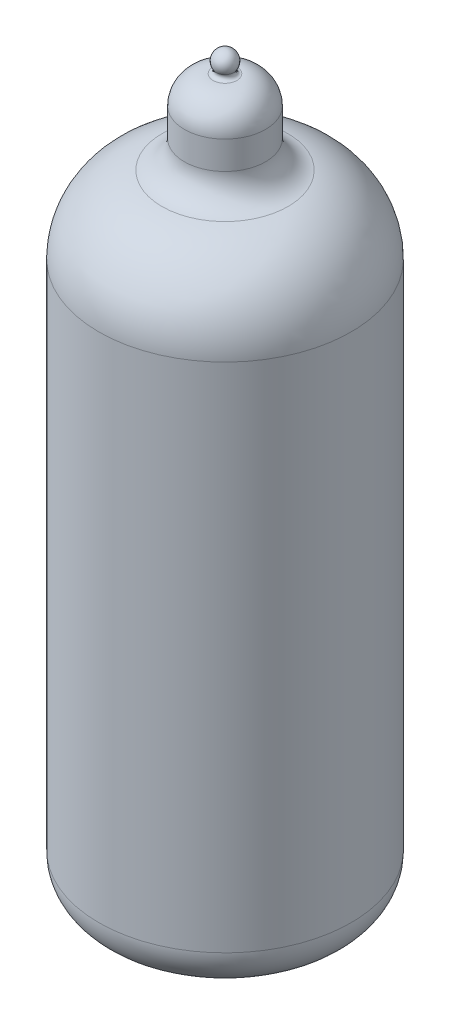
from build123d import *

# Parameters (mm, degrees)
CUT_EXTRUDE1_REACH = 54.5
SKETCH2_R          = 0.25
SKETCH3_R          = 3
CUT_EXTRUDE2_DEPTH = 0.5
CUT_EXTRUDE2_TAPER = 15


with BuildPart() as part:
    # Sketch1 → Revolve1 (revolve)
    with BuildSketch(Plane.XY):
        with BuildLine():
            Line((0, -26.25), (-6, -26.25))
            ThreePointArc((-6, -26.25), (-8.121320344, -25.371320344), (-9, -23.25))
            Line((-9, -23.25), (-9, 13.25))
            ThreePointArc((-9, 13.25), (-7.73164929, 16.803167601), (-4.5, 18.75))
            ThreePointArc((-4.5, 18.75), (-3.348125006, 19.443920459), (-2.896039604, 20.71039604))
            Line((-2.896039604, 20.71039604), (-2.896039604, 22.71039604))
            ThreePointArc((-2.896039604, 22.71039604), (-2.293006224, 24.141648729), (-0.847555343, 24.709808272))
            ThreePointArc((-0.847555343, 24.709808272), (-0.623570884, 24.837222914), (-0.631121107, 25.094801101))
            ThreePointArc((-0.631121107, 25.094801101), (-0.658178993, 25.859583666), (0, 26.25))
            Line((0, 26.25), (0, 24.21039604))
            Line((0, 24.21039604), (-0.896039604, 24.21039604))
            ThreePointArc((-0.896039604, 24.21039604), (-1.956699776, 23.771056211), (-2.396039604, 22.71039604))
            Line((-2.396039604, 22.71039604), (-2.396039604, 20.71039604))
            ThreePointArc((-2.396039604, 20.71039604), (-2.961146356, 19.127301564), (-4.400990099, 18.25990099))
            ThreePointArc((-4.400990099, 18.25990099), (-7.34467064, 16.486548706), (-8.5, 13.25))
            Line((-8.5, 13.25), (-8.5, -21.25))
            ThreePointArc((-8.5, -21.25), (-8.207106781, -21.957106781), (-7.5, -22.25))
            Line((-7.5, -22.25), (0, -22.25))
            Line((0, -22.25), (0, -26.25))
        make_face()
    revolve(axis=Axis((0, 26.25, 0), (0, -1, 0)))

    # Sketch2 → Cut-Extrude1 (cut, up to next)
    with BuildSketch(Plane.XZ.offset(26.25), mode=Mode.PRIVATE) as cut_extrude1_sk1:
        with Locations((0, -5.75)):
            Circle(SKETCH2_R)
    cut_extrude1_tool1 = extrude(cut_extrude1_sk1.sketch, amount=-CUT_EXTRUDE1_REACH, mode=Mode.PRIVATE) & part.part
    add(cut_extrude1_tool1.solids().sort_by_distance((0, -26.25, -5.75))[0], mode=Mode.SUBTRACT)
    # Sketch2 → Cut-Extrude1 (cut, up to next)
    with BuildSketch(Plane.XZ.offset(26.25), mode=Mode.PRIVATE) as cut_extrude1_sk2:
        with Locations((-2.672158239, -5.091372148)):
            Circle(SKETCH2_R)
    cut_extrude1_tool2 = extrude(cut_extrude1_sk2.sketch, amount=-CUT_EXTRUDE1_REACH, mode=Mode.PRIVATE) & part.part
    add(cut_extrude1_tool2.solids().sort_by_distance((-2.672158, -26.25, -5.091372))[0], mode=Mode.SUBTRACT)
    # Sketch2 → Cut-Extrude1 (cut, up to next)
    with BuildSketch(Plane.XZ.offset(26.25), mode=Mode.PRIVATE) as cut_extrude1_sk3:
        with Locations((-4.732157229, -3.266372294)):
            Circle(SKETCH2_R)
    cut_extrude1_tool3 = extrude(cut_extrude1_sk3.sketch, amount=-CUT_EXTRUDE1_REACH, mode=Mode.PRIVATE) & part.part
    add(cut_extrude1_tool3.solids().sort_by_distance((-4.732157, -26.25, -3.266372))[0], mode=Mode.SUBTRACT)
    # Sketch2 → Cut-Extrude1 (cut, up to next)
    with BuildSketch(Plane.XZ.offset(26.25), mode=Mode.PRIVATE) as cut_extrude1_sk4:
        with Locations((-5.708076026, -0.693085911)):
            Circle(SKETCH2_R)
    cut_extrude1_tool4 = extrude(cut_extrude1_sk4.sketch, amount=-CUT_EXTRUDE1_REACH, mode=Mode.PRIVATE) & part.part
    add(cut_extrude1_tool4.solids().sort_by_distance((-5.708076, -26.25, -0.693086))[0], mode=Mode.SUBTRACT)
    # Sketch2 → Cut-Extrude1 (cut, up to next)
    with BuildSketch(Plane.XZ.offset(26.25), mode=Mode.PRIVATE) as cut_extrude1_sk5:
        with Locations((-5.376343395, 2.0389781)):
            Circle(SKETCH2_R)
    cut_extrude1_tool5 = extrude(cut_extrude1_sk5.sketch, amount=-CUT_EXTRUDE1_REACH, mode=Mode.PRIVATE) & part.part
    add(cut_extrude1_tool5.solids().sort_by_distance((-5.376343, -26.25, 2.038978))[0], mode=Mode.SUBTRACT)
    # Sketch2 → Cut-Extrude1 (cut, up to next)
    with BuildSketch(Plane.XZ.offset(26.25), mode=Mode.PRIVATE) as cut_extrude1_sk6:
        with Locations((-3.812955285, 4.303936802)):
            Circle(SKETCH2_R)
    cut_extrude1_tool6 = extrude(cut_extrude1_sk6.sketch, amount=-CUT_EXTRUDE1_REACH, mode=Mode.PRIVATE) & part.part
    add(cut_extrude1_tool6.solids().sort_by_distance((-3.812955, -26.25, 4.303937))[0], mode=Mode.SUBTRACT)
    # Sketch2 → Cut-Extrude1 (cut, up to next)
    with BuildSketch(Plane.XZ.offset(26.25), mode=Mode.PRIVATE) as cut_extrude1_sk7:
        with Locations((-1.37606507, 5.58291545)):
            Circle(SKETCH2_R)
    cut_extrude1_tool7 = extrude(cut_extrude1_sk7.sketch, amount=-CUT_EXTRUDE1_REACH, mode=Mode.PRIVATE) & part.part
    add(cut_extrude1_tool7.solids().sort_by_distance((-1.376065, -26.25, 5.582915))[0], mode=Mode.SUBTRACT)
    # Sketch2 → Cut-Extrude1 (cut, up to next)
    with BuildSketch(Plane.XZ.offset(26.25), mode=Mode.PRIVATE) as cut_extrude1_sk8:
        with Locations((1.37606507, 5.58291545)):
            Circle(SKETCH2_R)
    cut_extrude1_tool8 = extrude(cut_extrude1_sk8.sketch, amount=-CUT_EXTRUDE1_REACH, mode=Mode.PRIVATE) & part.part
    add(cut_extrude1_tool8.solids().sort_by_distance((1.376065, -26.25, 5.582915))[0], mode=Mode.SUBTRACT)
    # Sketch2 → Cut-Extrude1 (cut, up to next)
    with BuildSketch(Plane.XZ.offset(26.25), mode=Mode.PRIVATE) as cut_extrude1_sk9:
        with Locations((3.812955285, 4.303936802)):
            Circle(SKETCH2_R)
    cut_extrude1_tool9 = extrude(cut_extrude1_sk9.sketch, amount=-CUT_EXTRUDE1_REACH, mode=Mode.PRIVATE) & part.part
    add(cut_extrude1_tool9.solids().sort_by_distance((3.812955, -26.25, 4.303937))[0], mode=Mode.SUBTRACT)
    # Sketch2 → Cut-Extrude1 (cut, up to next)
    with BuildSketch(Plane.XZ.offset(26.25), mode=Mode.PRIVATE) as cut_extrude1_sk10:
        with Locations((5.376343395, 2.0389781)):
            Circle(SKETCH2_R)
    cut_extrude1_tool10 = extrude(cut_extrude1_sk10.sketch, amount=-CUT_EXTRUDE1_REACH, mode=Mode.PRIVATE) & part.part
    add(cut_extrude1_tool10.solids().sort_by_distance((5.376343, -26.25, 2.038978))[0], mode=Mode.SUBTRACT)
    # Sketch2 → Cut-Extrude1 (cut, up to next)
    with BuildSketch(Plane.XZ.offset(26.25), mode=Mode.PRIVATE) as cut_extrude1_sk11:
        with Locations((5.708076026, -0.693085911)):
            Circle(SKETCH2_R)
    cut_extrude1_tool11 = extrude(cut_extrude1_sk11.sketch, amount=-CUT_EXTRUDE1_REACH, mode=Mode.PRIVATE) & part.part
    add(cut_extrude1_tool11.solids().sort_by_distance((5.708076, -26.25, -0.693086))[0], mode=Mode.SUBTRACT)
    # Sketch2 → Cut-Extrude1 (cut, up to next)
    with BuildSketch(Plane.XZ.offset(26.25), mode=Mode.PRIVATE) as cut_extrude1_sk12:
        with Locations((4.732157229, -3.266372294)):
            Circle(SKETCH2_R)
    cut_extrude1_tool12 = extrude(cut_extrude1_sk12.sketch, amount=-CUT_EXTRUDE1_REACH, mode=Mode.PRIVATE) & part.part
    add(cut_extrude1_tool12.solids().sort_by_distance((4.732157, -26.25, -3.266372))[0], mode=Mode.SUBTRACT)
    # Sketch2 → Cut-Extrude1 (cut, up to next)
    with BuildSketch(Plane.XZ.offset(26.25), mode=Mode.PRIVATE) as cut_extrude1_sk13:
        with Locations((2.672158239, -5.091372148)):
            Circle(SKETCH2_R)
    cut_extrude1_tool13 = extrude(cut_extrude1_sk13.sketch, amount=-CUT_EXTRUDE1_REACH, mode=Mode.PRIVATE) & part.part
    add(cut_extrude1_tool13.solids().sort_by_distance((2.672158, -26.25, -5.091372))[0], mode=Mode.SUBTRACT)

    # Sketch3 → Cut-Extrude2 (cut)
    with BuildSketch(Plane.XZ.offset(26.25)):
        Circle(SKETCH3_R)
        Polygon((0.375, 2.5), (-0.375, 2.5), (-0.375, -0.75), (-0.75, -0.75), (0, -2.5), (0.75, -0.75), (0.375, -0.75), align=None, mode=Mode.SUBTRACT)
    extrude(amount=-CUT_EXTRUDE2_DEPTH, taper=CUT_EXTRUDE2_TAPER, mode=Mode.SUBTRACT)


solid = part.part
